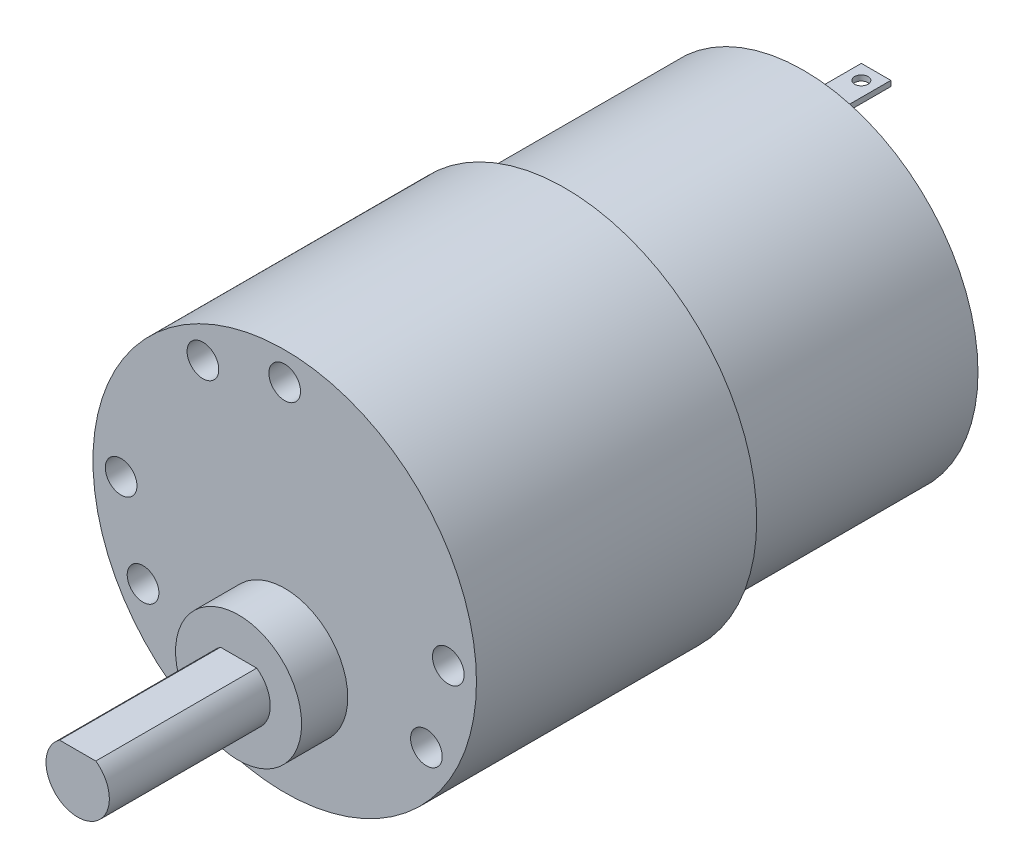
from build123d import *

# Parameters (mm, degrees)
SKETCH1_R           = 18.161
BOSS_EXTRUDE1_DEPTH = 26.543
SKETCH2_R           = 16.51
BOSS_EXTRUDE2_DEPTH = 22.606
SKETCH3_R           = 4.5085
BOSS_EXTRUDE3_DEPTH = 3.302
SKETCH4_R           = 2.413
BOSS_EXTRUDE4_DEPTH = 1.27
SKETCH5_R           = 5.969
BOSS_EXTRUDE5_DEPTH = 4.3688
BOSS_EXTRUDE6_DEPTH = 15.24
SKETCH8_W           = 5.588
SKETCH8_H           = 2.794
SKETCH8_R           = 0.635
BOSS_EXTRUDE7_DEPTH = 0.254
CIRPATTERN1_COUNT   = 2
CIRPATTERN2_COUNT   = 12


with BuildPart() as part:
    # Sketch1 → Boss-Extrude1 (new body)
    with BuildSketch(Plane.XY):
        Circle(SKETCH1_R)
    extrude(amount=BOSS_EXTRUDE1_DEPTH)

    # Sketch2 → Boss-Extrude2 (add)
    with BuildSketch(Plane(origin=(0, 0, 0), x_dir=(-1, 0, 0), z_dir=(0, 0, -1))):
        Circle(SKETCH2_R)
    extrude(amount=BOSS_EXTRUDE2_DEPTH)

    # Sketch3 → Boss-Extrude3 (add)
    with BuildSketch(Plane(origin=(0, 0, -22.606), x_dir=(-1, 0, 0), z_dir=(0, 0, -1))):
        Circle(SKETCH3_R)
    extrude(amount=BOSS_EXTRUDE3_DEPTH)

    # Sketch4 → Boss-Extrude4 (add)
    with BuildSketch(Plane(origin=(0, 0, -22.606), x_dir=(-1, 0, 0), z_dir=(0, 0, -1))):
        with Locations((0, -12.7)):
            Circle(SKETCH4_R)
        with Locations((0, 12.7)):
            Circle(SKETCH4_R)
    extrude(amount=BOSS_EXTRUDE4_DEPTH)

    # Sketch5 → Boss-Extrude5 (add)
    with BuildSketch(Plane.XY.offset(26.543)):
        with Locations((0, -7.366)):
            Circle(SKETCH5_R)
    extrude(amount=BOSS_EXTRUDE5_DEPTH)

    # Sketch6 → Boss-Extrude6 (add)
    with BuildSketch(Plane.XY.offset(30.9118)):
        with BuildLine():
            Line((-1.715657017, -4.905), (1.715657017, -4.905))
            ThreePointArc((1.715657017, -4.905), (0, -10.366), (-1.715657017, -4.905))
        make_face()
    extrude(amount=BOSS_EXTRUDE6_DEPTH)

    # Sketch8 → Boss-Extrude7 (add, symmetric)
    with BuildSketch(Plane.ZX.offset(12.7)):
        with Locations((-26.67, 0)):
            Rectangle(SKETCH8_W, SKETCH8_H)
        with Locations((-28.067, 0)):
            Circle(SKETCH8_R, mode=Mode.SUBTRACT)
    boss_extrude7 = extrude(amount=BOSS_EXTRUDE7_DEPTH, both=True)

    # CirPattern1: Boss-Extrude7 ×2 about axis
    cirpattern1_axis = Axis((0, 0, -25.908), (0, 0, 1))
    for i in range(1, CIRPATTERN1_COUNT):
        add(boss_extrude7.rotate(cirpattern1_axis, i * 360 / CIRPATTERN1_COUNT))

    # Sketch12 → Ø3.0mm Dowel Hole1 (revolve, cut)
    with BuildSketch(Plane(origin=(0, 15.494, 26.543), x_dir=(0, -1, 0), z_dir=(1, 0, 0))):
        Polygon((0, 0), (0, 11.061290929), (1.5, 10.16), (1.5, 0), align=None)
    f_3_0mm_dowel_hole1 = revolve(axis=Axis((0, 15.494, 32.893), (0, 0, -1)), mode=Mode.SUBTRACT)

    # CirPattern2: Ø3.0mm Dowel Hole1 ×12 about axis, 5 skipped
    cirpattern2_axis = Axis((0, 0, 26.543), (0, 0, -1))
    add([f_3_0mm_dowel_hole1.rotate(cirpattern2_axis, i * 360 / CIRPATTERN2_COUNT) for i in range(1, CIRPATTERN2_COUNT) if i not in (1, 2, 5, 6, 10)], mode=Mode.SUBTRACT)


solid = part.part
